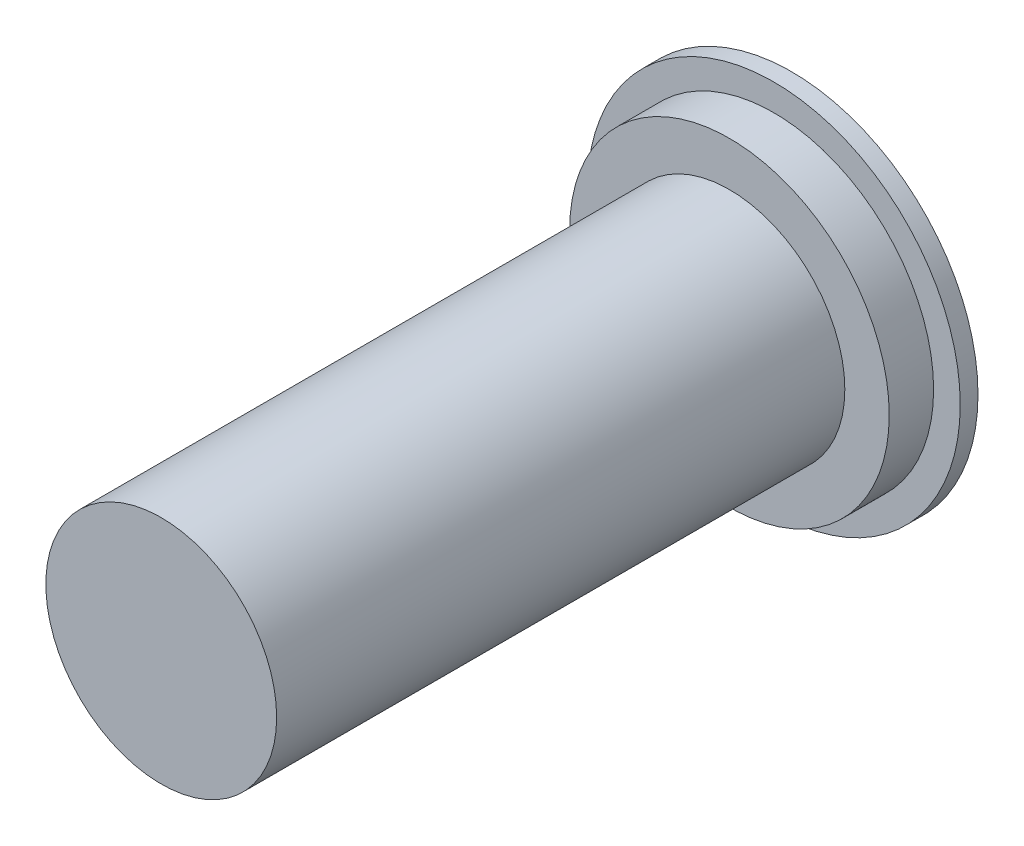
from build123d import *

# Parameters (mm, degrees)
SKETCH2_R           = 13
SKETCH2_R_2         = 12
BOSS_EXTRUDE1_DEPTH = 70
SKETCH2_3_R         = 18
SKETCH2_3_R_2       = 13
BOSS_EXTRUDE2_DEPTH = 7
SKETCH2_4_R         = 21
SKETCH2_4_R_2       = 18
BOSS_EXTRUDE3_DEPTH = 2
SKETCH3_R           = 13
BOSS_EXTRUDE4_DEPTH = 1


with BuildPart() as part:
    # Sketch2 → Boss-Extrude1 (new body)
    with BuildSketch(Plane.XY):
        Circle(SKETCH2_R)
        Circle(SKETCH2_R_2, mode=Mode.SUBTRACT)
    extrude(amount=BOSS_EXTRUDE1_DEPTH)

    # Sketch2_3 → Boss-Extrude2 (add)
    with BuildSketch(Plane.XY):
        Circle(SKETCH2_3_R)
        Circle(SKETCH2_3_R_2, mode=Mode.SUBTRACT)
    extrude(amount=BOSS_EXTRUDE2_DEPTH)

    # Sketch2_4 → Boss-Extrude3 (add)
    with BuildSketch(Plane.XY):
        Circle(SKETCH2_4_R)
        Circle(SKETCH2_4_R_2, mode=Mode.SUBTRACT)
    extrude(amount=BOSS_EXTRUDE3_DEPTH)

    # Sketch3 → Boss-Extrude4 (add)
    with BuildSketch(Plane.XY.offset(70)):
        Circle(SKETCH3_R)
    extrude(amount=BOSS_EXTRUDE4_DEPTH)


solid = part.part
